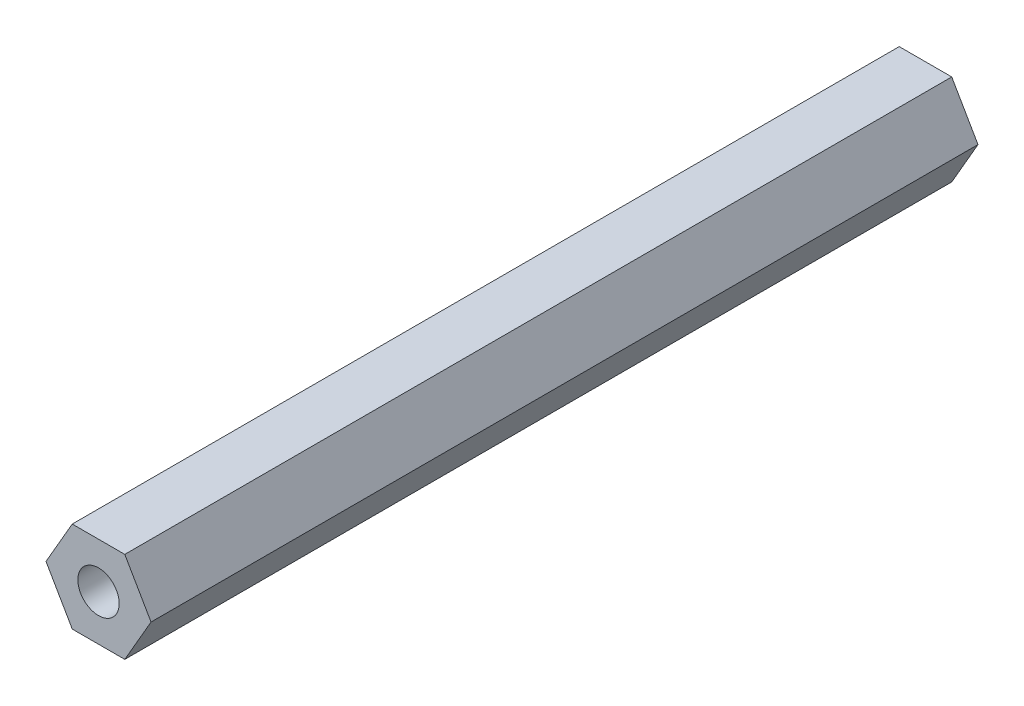
from build123d import *

# Parameters (mm, degrees)
BOSS_EXTRUDE1_DEPTH   = 50
M3X0_5_TAPPED_HOLE1_D = 2.5


with BuildPart() as part:
    # Sketch1 → Boss-Extrude1 (new body)
    with BuildSketch(Plane.XY):
        Polygon((3.175426481, 0), (1.58771324, 2.75), (-1.58771324, 2.75), (-3.175426481, 0), (-1.58771324, -2.75), (1.58771324, -2.75), align=None)
    extrude(amount=BOSS_EXTRUDE1_DEPTH)

    # M3x0.5 Tapped Hole1 (through all)
    with Locations(Plane.XY.offset(50)):
        with Locations((0, 0)):
            Hole(M3X0_5_TAPPED_HOLE1_D / 2)


solid = part.part
